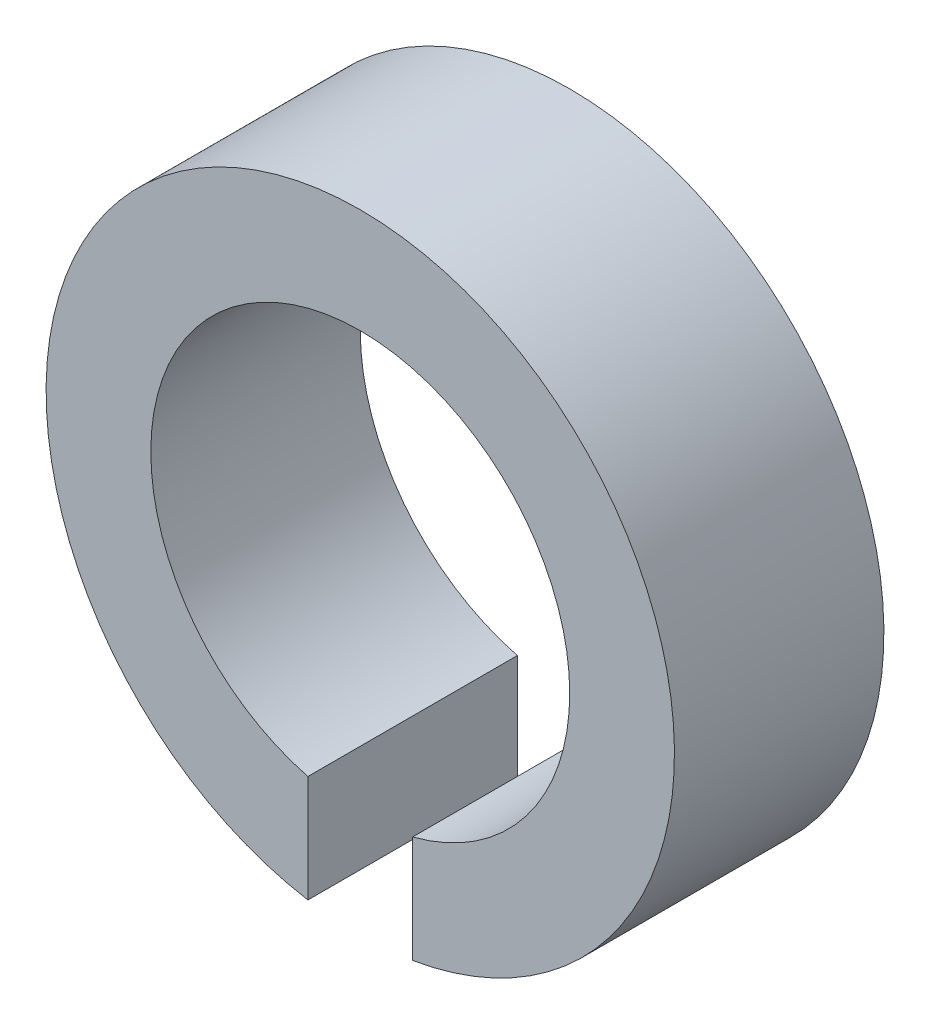
from build123d import *

# Parameters (mm, degrees)
BASE_EXTRUSION_DEPTH = 6


with BuildPart() as part:
    # Esquisse1 → Base-Extrusion (new body)
    with BuildSketch(Plane.XY):
        with BuildLine():
            Line((1.5, -5.809475019), (1.5, -8.874119675))
            ThreePointArc((1.5, -8.874119675), (0, 9), (-1.5, -8.874119675))
            Line((-1.5, -8.874119675), (-1.5, -5.809475019))
            ThreePointArc((-1.5, -5.809475019), (0, 6), (1.5, -5.809475019))
        make_face()
    extrude(amount=BASE_EXTRUSION_DEPTH)


solid = part.part
